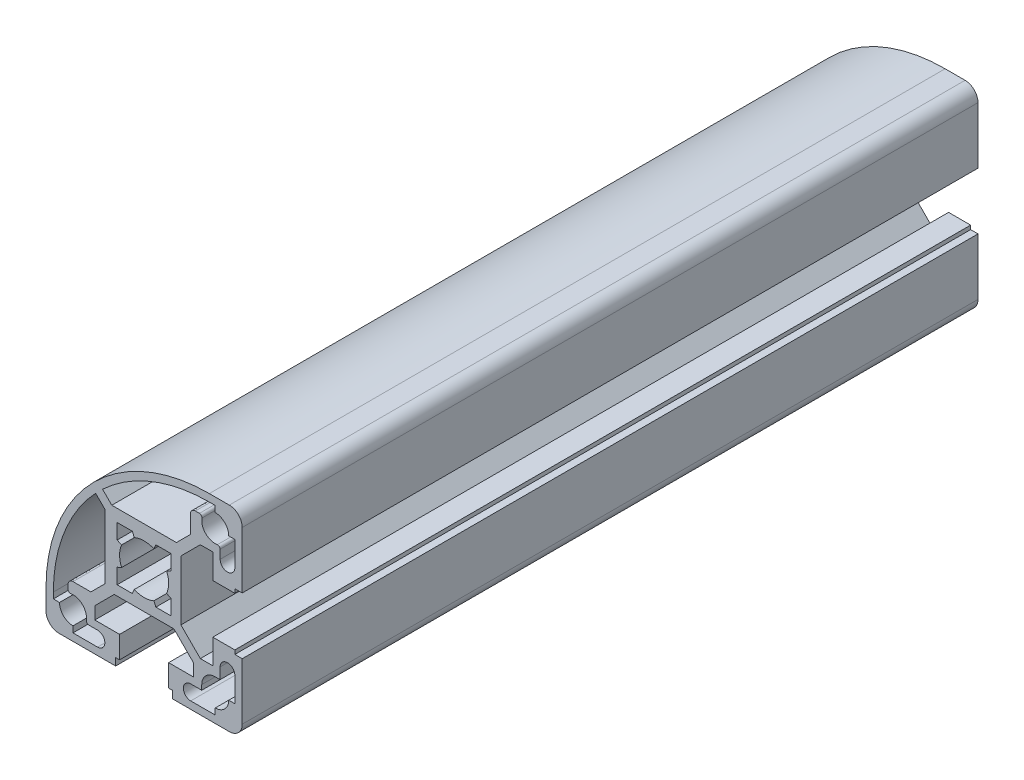
from build123d import *

# Parameters (mm, degrees)
EXTRUDE1_DEPTH = 150


with BuildPart() as part:
    # Sketch2 → Extrude1 (new body)
    with BuildSketch(Plane.XY):
        with BuildLine():
            Line((18.5, -5.8), (18.5, -5))
            Line((18.5, -5), (14, -5))
            Line((14, -5), (14, -10.05))
            Line((14, -10.05), (11.464213562, -10.05))
            Line((11.464213562, -10.05), (7.5, -6.085786438))
            Line((7.5, -6.085786438), (7.5, 6.085786438))
            Line((7.5, 6.085786438), (11.464213562, 10.05))
            Line((11.464213562, 10.05), (14, 10.05))
            Line((14, 10.05), (14, 5))
            Line((14, 5), (18.5, 5))
            Line((18.5, 5), (18.5, 5.8))
            Line((18.5, 5.8), (20, 5.8))
            Line((20, 5.8), (20, 17.369192104))
            ThreePointArc((20, 17.369192104), (19.229454207, 19.229454207), (17.369192104, 20))
            Line((17.369192104, 20), (13.3, 20))
            ThreePointArc((13.3, 20), (-10.246655814, 10.246655814), (-20, -13.3))
            Line((-20, -13.3), (-20, -17.369192104))
            ThreePointArc((-20, -17.369192104), (-19.229454207, -19.229454207), (-17.369192104, -20))
            Line((-17.369192104, -20), (-5.8, -20))
            Line((-5.8, -20), (-5.8, -18.5))
            Line((-5.8, -18.5), (-5, -18.5))
            Line((-5, -18.5), (-5, -14))
            Line((-5, -14), (-10.05, -14))
            Line((-10.05, -14), (-10.05, -11.464213562))
            Line((-10.05, -11.464213562), (-6.085786438, -7.5))
            Line((-6.085786438, -7.5), (6.085786438, -7.5))
            Line((6.085786438, -7.5), (10.05, -11.464213562))
            Line((10.05, -11.464213562), (10.05, -14))
            Line((10.05, -14), (5, -14))
            Line((5, -14), (5, -18.5))
            Line((5, -18.5), (5.8, -18.5))
            Line((5.8, -18.5), (5.8, -20))
            Line((5.8, -20), (17.369192104, -20))
            ThreePointArc((17.369192104, -20), (19.229454207, -19.229454207), (20, -17.369192104))
            Line((20, -17.369192104), (20, -5.8))
            Line((20, -5.8), (18.5, -5.8))
        make_face()
        with BuildLine():
            Line((2.397915762, 5.5), (1.998263135, 4.583333333))
            ThreePointArc((1.998263135, 4.583333333), (0, 5), (-1.998263135, 4.583333333))
            Line((-1.998263135, 4.583333333), (-2.397915762, 5.5))
            Line((-2.397915762, 5.5), (-5.5, 5.5))
            Line((-5.5, 5.5), (-5.5, 2.397915762))
            Line((-5.5, 2.397915762), (-4.583333333, 1.998263135))
            ThreePointArc((-4.583333333, 1.998263135), (-5, 0), (-4.583333333, -1.998263135))
            Line((-4.583333333, -1.998263135), (-5.5, -2.397915762))
            Line((-5.5, -2.397915762), (-5.5, -5.5))
            Line((-5.5, -5.5), (-2.397915762, -5.5))
            Line((-2.397915762, -5.5), (-1.998263135, -4.583333333))
            ThreePointArc((-1.998263135, -4.583333333), (0, -5), (1.998263135, -4.583333333))
            Line((1.998263135, -4.583333333), (2.397915762, -5.5))
            Line((2.397915762, -5.5), (5.5, -5.5))
            Line((5.5, -5.5), (5.5, -2.397915762))
            Line((5.5, -2.397915762), (4.583333333, -1.998263135))
            ThreePointArc((4.583333333, -1.998263135), (5, 0), (4.583333333, 1.998263135))
            Line((4.583333333, 1.998263135), (5.5, 2.397915762))
            Line((5.5, 2.397915762), (5.5, 5.5))
            Line((5.5, 5.5), (2.397915762, 5.5))
        make_face(mode=Mode.SUBTRACT)
        with BuildLine():
            Line((9.438262309, 10.852475871), (6.585786438, 8))
            Line((6.585786438, 8), (-6.585786438, 8))
            Line((-6.585786438, 8), (-8.467768079, 9.881981642))
            ThreePointArc((-8.467768079, 9.881981642), (1.586686602, 16.264138568), (13.28390541, 18.499995927))
            Line((13.28390541, 18.499995927), (14.5, 18.500611416))
            Line((14.5, 18.500611416), (14.5, 17.25))
            ThreePointArc((14.5, 17.25), (16.444543648, 16.444543648), (17.25, 14.5))
            Line((17.25, 14.5), (18.5, 14.5))
            Line((18.5, 14.5), (18.5, 9.5))
            ThreePointArc((18.5, 9.5), (17, 8), (15.5, 9.5))
            Line((15.5, 9.5), (15.5, 11.288691855))
            ThreePointArc((15.5, 11.288691855), (15.325221818, 11.668469118), (14.923076923, 11.782739262))
            ThreePointArc((14.923076923, 11.782739262), (12.555456352, 12.555456352), (11.782739262, 14.923076923))
            ThreePointArc((11.782739262, 14.923076923), (11.668469118, 15.325221818), (11.288691855, 15.5))
            Line((11.288691855, 15.5), (10.438262309, 15.5))
            ThreePointArc((10.438262309, 15.5), (9.731155527, 15.207106781), (9.438262309, 14.5))
            Line((9.438262309, 14.5), (9.438262309, 10.852475871))
        make_face(mode=Mode.SUBTRACT)
        with BuildLine():
            Line((11.75, -15.5), (11.75, -14.5))
            ThreePointArc((11.75, -14.5), (12.555456352, -12.555456352), (14.5, -11.75))
            Line((14.5, -11.75), (15.5, -11.75))
            Line((15.5, -11.75), (15.5, -9.5))
            ThreePointArc((15.5, -9.5), (17, -8), (18.5, -9.5))
            Line((18.5, -9.5), (18.5, -14.5))
            Line((18.5, -14.5), (17.25, -14.5))
            ThreePointArc((17.25, -14.5), (16.444543648, -16.444543648), (14.5, -17.25))
            Line((14.5, -17.25), (14.5, -18.5))
            Line((14.5, -18.5), (9.5, -18.5))
            ThreePointArc((9.5, -18.5), (8, -17), (9.5, -15.5))
            Line((9.5, -15.5), (11.75, -15.5))
        make_face(mode=Mode.SUBTRACT)
        with BuildLine():
            Line((-18.500611416, -14.5), (-18.499995927, -13.28390541))
            ThreePointArc((-18.499995927, -13.28390541), (-16.264138568, -1.586686602), (-9.881981642, 8.467768079))
            Line((-9.881981642, 8.467768079), (-8, 6.585786438))
            Line((-8, 6.585786438), (-8, -6.585786438))
            Line((-8, -6.585786438), (-10.852475871, -9.438262309))
            Line((-10.852475871, -9.438262309), (-14.5, -9.438262309))
            ThreePointArc((-14.5, -9.438262309), (-15.207106781, -9.731155527), (-15.5, -10.438262309))
            Line((-15.5, -10.438262309), (-15.5, -11.288691855))
            ThreePointArc((-15.5, -11.288691855), (-15.325221818, -11.668469118), (-14.923076923, -11.782739262))
            ThreePointArc((-14.923076923, -11.782739262), (-12.555456352, -12.555456352), (-11.782739262, -14.923076923))
            ThreePointArc((-11.782739262, -14.923076923), (-11.668469118, -15.325221818), (-11.288691855, -15.5))
            Line((-11.288691855, -15.5), (-9.5, -15.5))
            ThreePointArc((-9.5, -15.5), (-8, -17), (-9.5, -18.5))
            Line((-9.5, -18.5), (-14.5, -18.5))
            Line((-14.5, -18.5), (-14.5, -17.25))
            ThreePointArc((-14.5, -17.25), (-16.444543648, -16.444543648), (-17.25, -14.5))
            Line((-17.25, -14.5), (-18.500611416, -14.5))
        make_face(mode=Mode.SUBTRACT)
    extrude(amount=-EXTRUDE1_DEPTH)


solid = part.part
